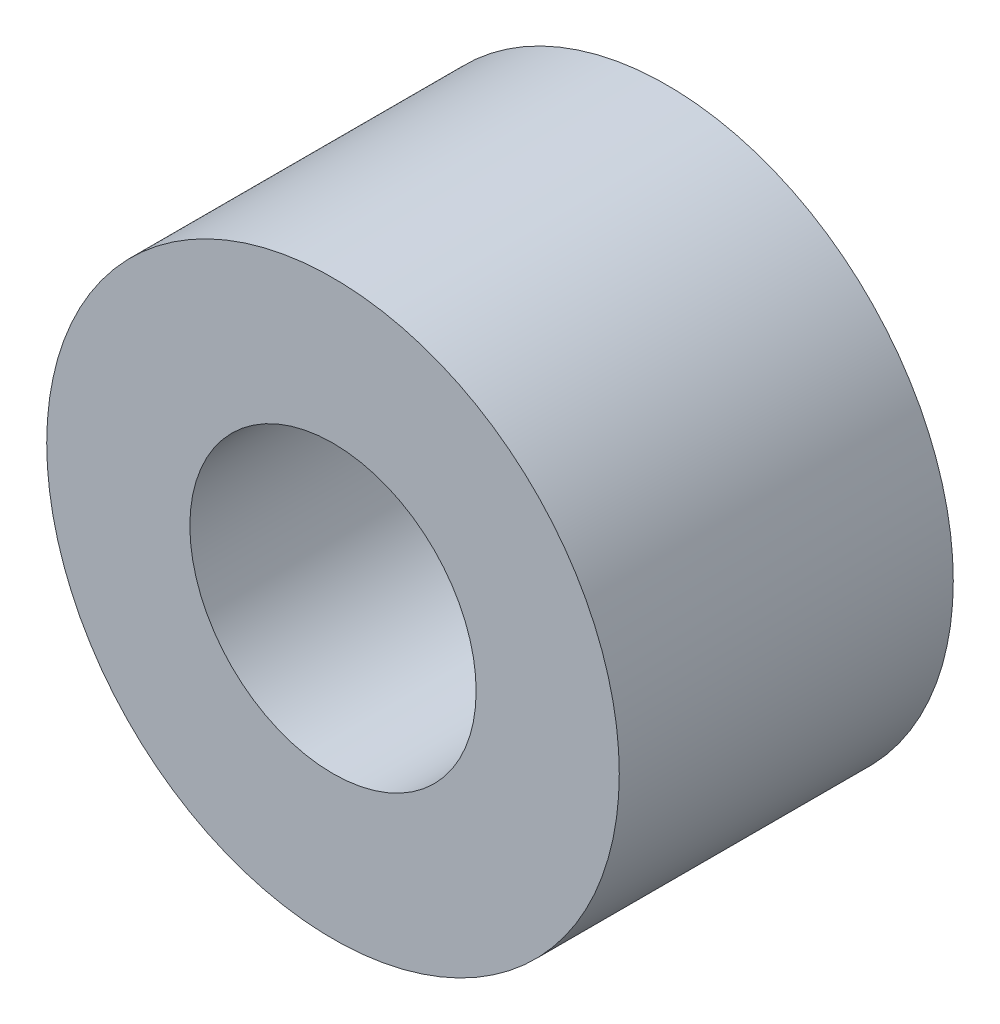
from build123d import *

# Parameters (mm, degrees)
EXTRUDE_START   = 3
SKETCH_1_R      = 6
SKETCH_1_R_2    = 3
EXTRUDE_1_DEPTH = 7


with BuildPart() as part:
    # ｽｹｯﾁ1 → ﾎﾞｽ - 押し出し1 (new body)
    with BuildSketch(Plane.XY.offset(EXTRUDE_START)):
        with Locations((8, 30)):
            Circle(SKETCH_1_R)
        with Locations((8, 30)):
            Circle(SKETCH_1_R_2, mode=Mode.SUBTRACT)
    extrude(amount=EXTRUDE_1_DEPTH)


solid = part.part
